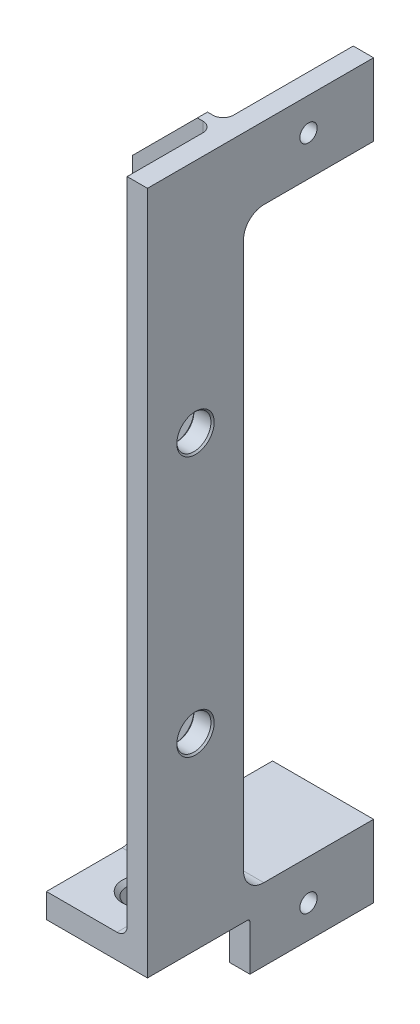
from build123d import *

# Parameters (mm, degrees)
BOSS_EXTRUDE1_DEPTH   = 3.175
BOSS_EXTRUDE2_DEPTH   = 12.60732
FILLET1_R             = 1.5875
FILLET2_R             = 3.175
CUT_EXTRUDE1_DEPTH    = 16
F_6_32_TAPPED_HOLE1_D = 2.7051
SKETCH10_R            = 2.667
CUT_EXTRUDE2_DEPTH    = 4.175
CHAMFER1_SIZE         = 0.254
FILLET3_R             = 1.5875
FILLET4_R             = 0.39624


with BuildPart() as part:
    # Sketch1 → Boss-Extrude1 (new body)
    with BuildSketch(Plane(origin=(0, 0, 0), x_dir=(0, 0, -1), z_dir=(1, 0, 0))):
        Polygon((27.813, 57.15), (27.813, 45.847999998), (7.5, 45.847999998), (7.5, -45.847999998), (27.813, -45.847999998), (27.813, -57.15), (8.5, -57.15), (8.5, -49.657999998), (-7.5, -49.657999998), (-7.5, 57.15), align=None)
    extrude(amount=BOSS_EXTRUDE1_DEPTH)

    # Sketch2 → Boss-Extrude2 (add)
    with BuildSketch(Plane.ZY):
        Polygon((7.5, -49.657999998), (7.5, -45.847999998), (-5.9125, -45.847999998), (-5.9125, 57.15), (-7.5, 57.15), (-7.5, -45.847999998), (-27.813, -45.847999998), (-27.813, -49.657999998), align=None)
    extrude(amount=BOSS_EXTRUDE2_DEPTH)

    # Sketch4 → #10 Clearance Hole1 (revolve, cut)
    with BuildSketch(Plane(origin=(-5.10794, -49.657999998, 0), x_dir=(0, 0, -1), z_dir=(1, 0, 0))):
        Polygon((0, 0), (0, 3.81), (3.1242, 3.81), (2.4892, 3.175), (2.4892, 0.635), (3.1242, 0), align=None)
    revolve(axis=Axis((-5.10794, -56.007999998, 0), (0, 1, 0)), mode=Mode.SUBTRACT)

    # Fillet1
    fillet1_edges = [part.edges().sort_by_distance(p)[0] for p in [
        (-6.30366, -45.847999998, -5.9125),
    ]]
    fillet(fillet1_edges, radius=FILLET1_R)

    # Fillet2
    fillet2_edges = [part.edges().sort_by_distance(p)[0] for p in [
        (-4.71616, -45.847999998, -7.5),
        (1.5875, 45.847999998, -7.5),
    ]]
    fillet(fillet2_edges, radius=FILLET2_R)

    # Sketch6 → Cut-Extrude1 (cut, through all)
    with BuildSketch(Plane(origin=(0, 0, -7.5), x_dir=(-1, 0, 0), z_dir=(0, 0, -1))):
        Polygon((2.447319972, 57.15), (12.607319972, 57.15), (12.607319972, 46.99), align=None)
    extrude(amount=-CUT_EXTRUDE1_DEPTH, mode=Mode.SUBTRACT)

    # #6-32 Tapped Hole1 (through all)
    with Locations(Plane(origin=(3.175, 0, 0), x_dir=(0, 0, -1), z_dir=(1, 0, 0))):
        with Locations((17.653, 52.07)):
            f_6_32_tapped_hole1 = Hole(F_6_32_TAPPED_HOLE1_D / 2)

    # Sketch10 → Cut-Extrude2 (cut, through all)
    with BuildSketch(Plane.ZY):
        with Locations((0, 20.32)):
            Circle(SKETCH10_R)
    cut_extrude2 = extrude(amount=-CUT_EXTRUDE2_DEPTH, mode=Mode.SUBTRACT)

    # Mirror2: Cut-Extrude2 across plane
    add(cut_extrude2.mirror(Plane.ZX), mode=Mode.SUBTRACT)

    # Chamfer1
    chamfer1_edges = [part.edges().sort_by_distance(p)[0] for p in [
        (3.175, 20.32, -2.667),
        (0, 20.32, -2.667),
        (3.175, -20.32, -2.667),
        (0, -20.32, -2.667),
    ]]
    chamfer(chamfer1_edges, length=CHAMFER1_SIZE)

    # Fillet3
    fillet3_edges = [part.edges().sort_by_distance(p)[0] for p in [
        (0, 6.444750001, -5.9125),
        (0, -45.383032013, -5.447532015),
        (0, -49.657999998, -18.1565),
        (0, 49.911499999, -7.5),
        (0, -45.847999998, 1.5875),
    ]]
    fillet(fillet3_edges, radius=FILLET3_R)

    # Mirror1: #6-32 Tapped Hole1 across plane
    add(f_6_32_tapped_hole1.mirror(Plane.ZX), mode=Mode.SUBTRACT)

    # Fillet4
    fillet4_edges = [part.edges().sort_by_distance(p)[0] for p in [
        (0.79375, -49.657999998, -8.5),
    ]]
    fillet(fillet4_edges, radius=FILLET4_R)


solid = part.part
